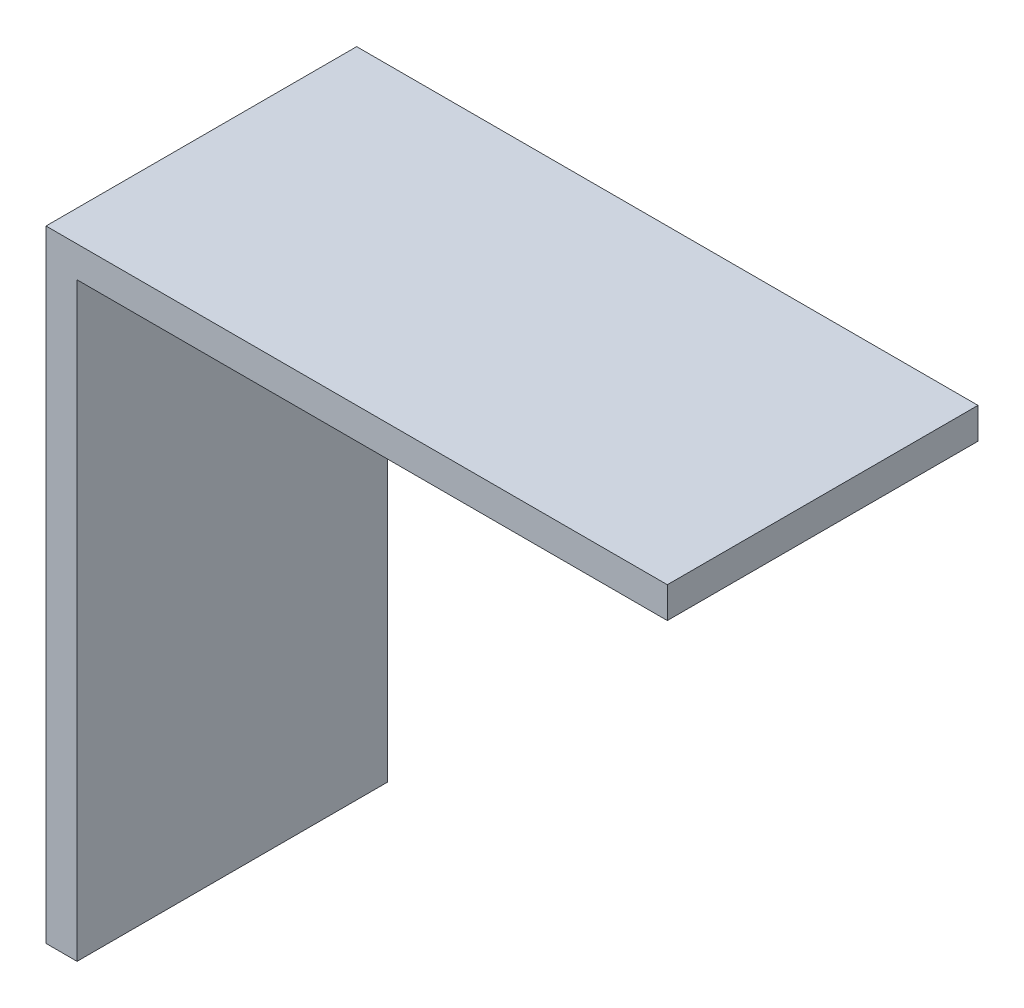
from build123d import *

# Parameters (mm, degrees)
SKETCH1_W           = 40
SKETCH1_H           = 20
BOSS_EXTRUDE1_DEPTH = 2
SKETCH2_W           = 2
SKETCH2_H           = 20
BOSS_EXTRUDE2_DEPTH = 38


with BuildPart() as part:
    # Sketch1 → Boss-Extrude1 (new body)
    with BuildSketch(Plane(origin=(0, 0, 0), x_dir=(1, 0, 0), z_dir=(0, 1, 0))):
        Rectangle(SKETCH1_W, SKETCH1_H)
    extrude(amount=BOSS_EXTRUDE1_DEPTH)

    # Sketch2 → Boss-Extrude2 (add)
    with BuildSketch(Plane.XZ):
        with Locations((-19, 0)):
            Rectangle(SKETCH2_W, SKETCH2_H)
    extrude(amount=BOSS_EXTRUDE2_DEPTH)


solid = part.part
